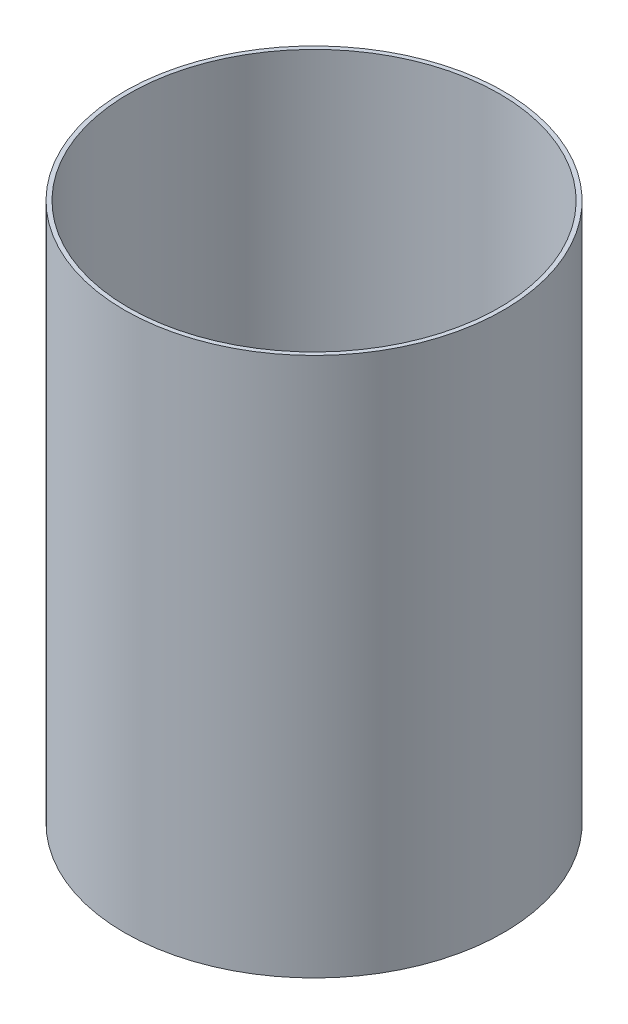
from build123d import *

# Parameters (mm, degrees)
SKETCH5_R           = 142.875
SKETCH5_R_2         = 139.7
BOSS_EXTRUDE1_DEPTH = 406.4


with BuildPart() as part:
    # Sketch5 → Boss-Extrude1 (new body)
    with BuildSketch(Plane(origin=(0, 0, 0), x_dir=(1, 0, 0), z_dir=(0, 1, 0))):
        Circle(SKETCH5_R)
        Circle(SKETCH5_R_2, mode=Mode.SUBTRACT)
    extrude(amount=BOSS_EXTRUDE1_DEPTH)


solid = part.part
